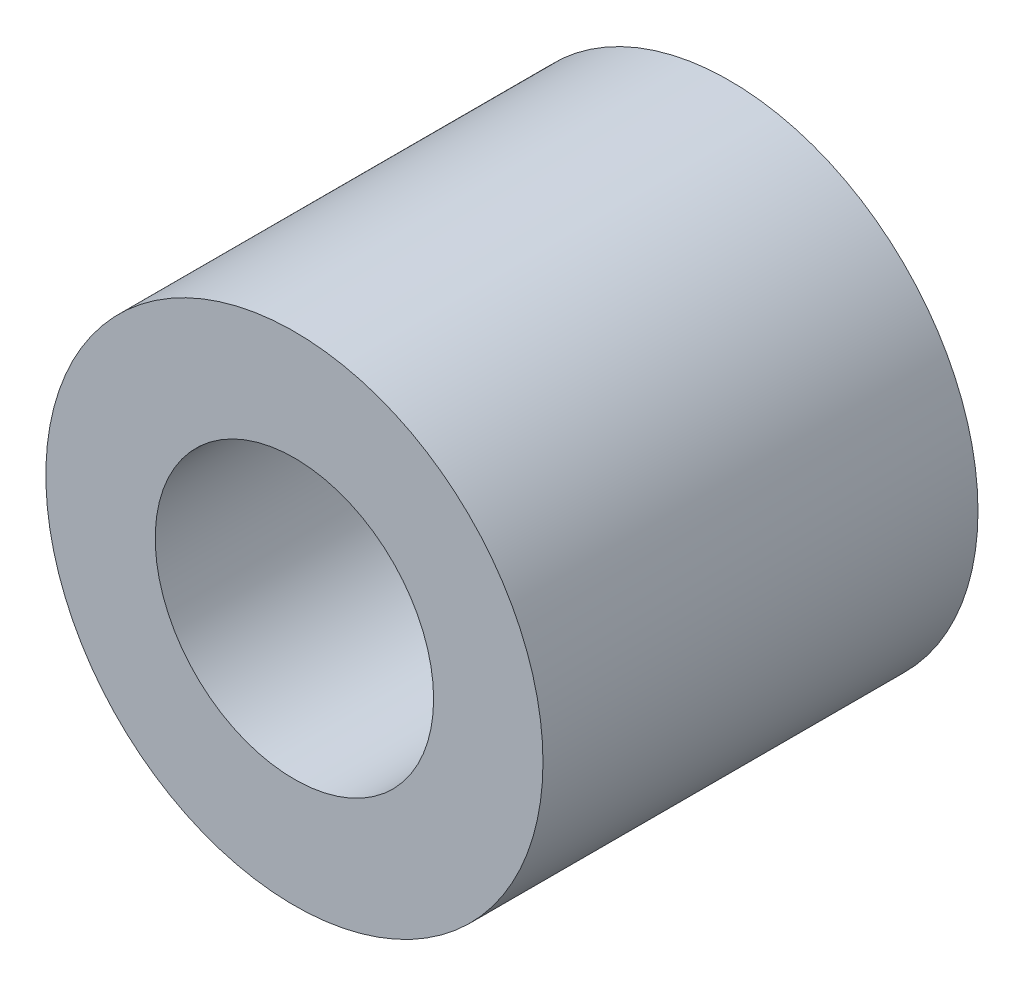
from build123d import *

# Parameters (mm, degrees)
SKETCH1_R      = 3.175
SKETCH1_R_2    = 1.778
EXTRUDE1_DEPTH = 2.778125


with BuildPart() as part:
    # Sketch1 → Extrude1 (new body, symmetric)
    with BuildSketch(Plane.XY):
        Circle(SKETCH1_R)
        Circle(SKETCH1_R_2, mode=Mode.SUBTRACT)
    extrude(amount=EXTRUDE1_DEPTH, both=True)


solid = part.part
